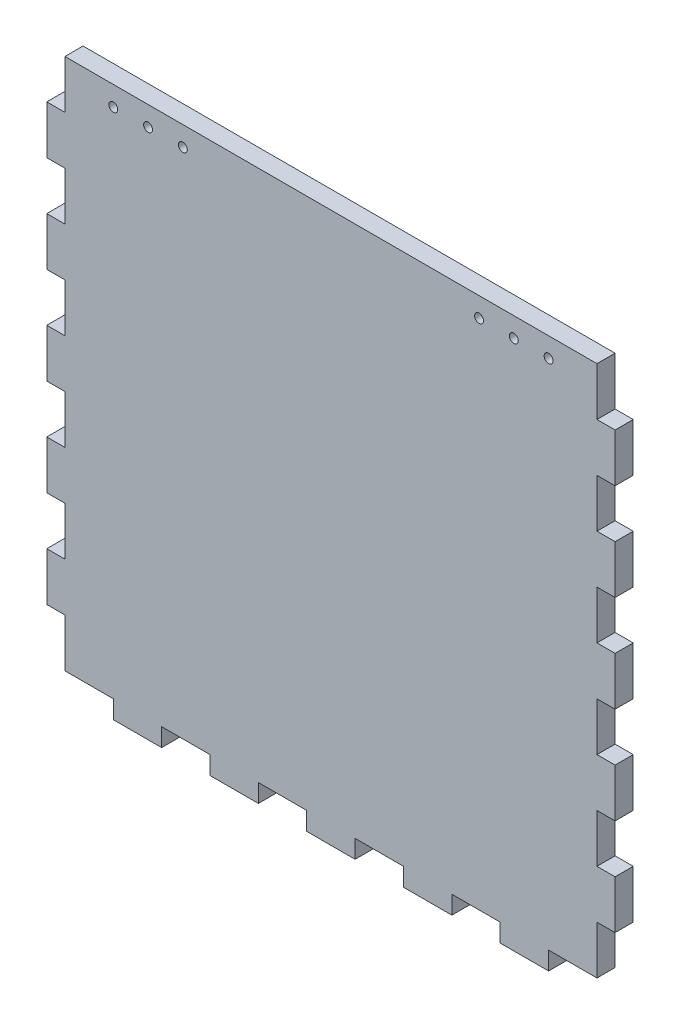
from build123d import *

# Parameters (mm, degrees)
SKETCH2_W               = 279.4
SKETCH2_H               = 279.4
BOSS_EXTRUDE1_DEPTH     = 9.525
SKETCH4_W               = 9.525
SKETCH4_H               = 25.4
BOSS_EXTRUDE3_DEPTH     = 9.525
LPATTERN2_COUNT         = 5
LPATTERN2_PITCH         = 50.8
MIRROR2_COPY_1_SKETCH_W = 9.525
MIRROR2_COPY_1_SKETCH_H = 25.4
MIRROR2_COPY_1_DEPTH    = 9.525
MIRROR2_COPY_2_SKETCH_W = 9.525
MIRROR2_COPY_2_SKETCH_H = 25.4
MIRROR2_COPY_2_DEPTH    = 9.525
MIRROR2_COPY_3_SKETCH_W = 9.525
MIRROR2_COPY_3_SKETCH_H = 25.4
MIRROR2_COPY_3_DEPTH    = 9.525
MIRROR2_COPY_4_SKETCH_W = 9.525
MIRROR2_COPY_4_SKETCH_H = 25.4
MIRROR2_COPY_4_DEPTH    = 9.525
SKETCH5_W               = 25.4
SKETCH5_H               = 9.525
BOSS_EXTRUDE4_DEPTH     = 9.525
LPATTERN3_COUNT         = 5
LPATTERN3_PITCH         = 50.8
SKETCH6_R               = 2.3368
CUT_EXTRUDE1_DEPTH      = 10.525


with BuildPart() as part:
    # Sketch2 → Boss-Extrude1 (new body)
    with BuildSketch(Plane.XY):
        Rectangle(SKETCH2_W, SKETCH2_H)
    extrude(amount=BOSS_EXTRUDE1_DEPTH)

    # Sketch4 → Boss-Extrude3 (add)
    with BuildSketch(Plane(origin=(139.7, 0, 0), x_dir=(0, 0, -1), z_dir=(1, 0, 0))):
        with Locations((-4.7625, -101.6)):
            Rectangle(SKETCH4_W, SKETCH4_H)
    boss_extrude3 = extrude(amount=BOSS_EXTRUDE3_DEPTH)

    # LPattern2: Boss-Extrude3 ×5
    with Locations(*[(0, i * LPATTERN2_PITCH, 0) for i in range(1, LPATTERN2_COUNT)]):
        add(boss_extrude3)

    # Mirror2: Boss-Extrude3 across plane
    add(boss_extrude3.mirror(Plane(origin=(0, 0, 0), x_dir=(0, 0, 1), z_dir=(1, 0, 0))))

    # Mirror2 copy 1 sketch → Mirror2 copy 1 (add)
    with BuildSketch(Plane(origin=(-139.7, 50.8, 0), x_dir=(0, 0, -1), z_dir=(-1, 0, 0))):
        with Locations((-4.7625, 101.6)):
            Rectangle(MIRROR2_COPY_1_SKETCH_W, MIRROR2_COPY_1_SKETCH_H)
    extrude(amount=MIRROR2_COPY_1_DEPTH)

    # Mirror2 copy 2 sketch → Mirror2 copy 2 (add)
    with BuildSketch(Plane(origin=(-139.7, 101.6, 0), x_dir=(0, 0, -1), z_dir=(-1, 0, 0))):
        with Locations((-4.7625, 101.6)):
            Rectangle(MIRROR2_COPY_2_SKETCH_W, MIRROR2_COPY_2_SKETCH_H)
    extrude(amount=MIRROR2_COPY_2_DEPTH)

    # Mirror2 copy 3 sketch → Mirror2 copy 3 (add)
    with BuildSketch(Plane(origin=(-139.7, 152.4, 0), x_dir=(0, 0, -1), z_dir=(-1, 0, 0))):
        with Locations((-4.7625, 101.6)):
            Rectangle(MIRROR2_COPY_3_SKETCH_W, MIRROR2_COPY_3_SKETCH_H)
    extrude(amount=MIRROR2_COPY_3_DEPTH)

    # Mirror2 copy 4 sketch → Mirror2 copy 4 (add)
    with BuildSketch(Plane(origin=(-139.7, 203.2, 0), x_dir=(0, 0, -1), z_dir=(-1, 0, 0))):
        with Locations((-4.7625, 101.6)):
            Rectangle(MIRROR2_COPY_4_SKETCH_W, MIRROR2_COPY_4_SKETCH_H)
    extrude(amount=MIRROR2_COPY_4_DEPTH)

    # Sketch5 → Boss-Extrude4 (add)
    with BuildSketch(Plane.XZ.offset(139.7)):
        with Locations((-101.6, 4.7625)):
            Rectangle(SKETCH5_W, SKETCH5_H)
    boss_extrude4 = extrude(amount=BOSS_EXTRUDE4_DEPTH)

    # LPattern3: Boss-Extrude4 ×5
    with Locations(*[(i * LPATTERN3_PITCH, 0, 0) for i in range(1, LPATTERN3_COUNT)]):
        add(boss_extrude4)

    # Sketch6 → Cut-Extrude1 (cut, through all)
    with BuildSketch(Plane.XY.offset(9.525)):
        with Locations((114.3, 129.3876)):
            Circle(SKETCH6_R)
        with Locations((77.7748, 129.3876)):
            Circle(SKETCH6_R)
        with Locations((96.0374, 129.3876)):
            Circle(SKETCH6_R)
    cut_extrude1 = extrude(amount=-CUT_EXTRUDE1_DEPTH, mode=Mode.SUBTRACT)

    # Mirror3: Cut-Extrude1 across plane
    add(cut_extrude1.mirror(Plane(origin=(0, 0, 0), x_dir=(0, 0, 1), z_dir=(1, 0, 0))), mode=Mode.SUBTRACT)


solid = part.part
